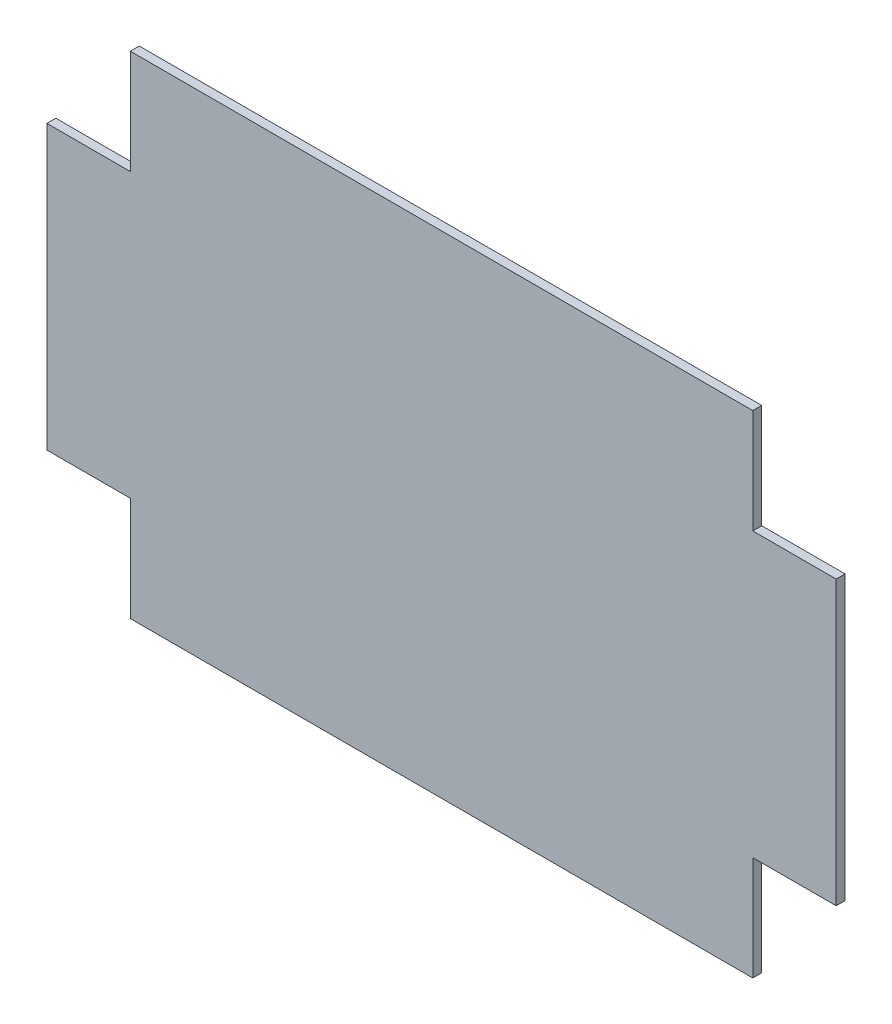
from build123d import *

# Parameters (mm, degrees)
BOSS_EXTRUDE1_DEPTH = 3


with BuildPart() as part:
    # Sketch1 → Boss-Extrude1 (new body)
    with BuildSketch(Plane.XY):
        Polygon((104.5, 82.5), (-104.5, 82.5), (-104.5, 47.5), (-132.5, 47.5), (-132.5, -47.5), (-104.5, -47.5), (-104.5, -82.5), (104.5, -82.5), (104.5, -47.5), (132.5, -47.5), (132.5, 47.5), (104.5, 47.5), align=None)
    extrude(amount=BOSS_EXTRUDE1_DEPTH)


solid = part.part
